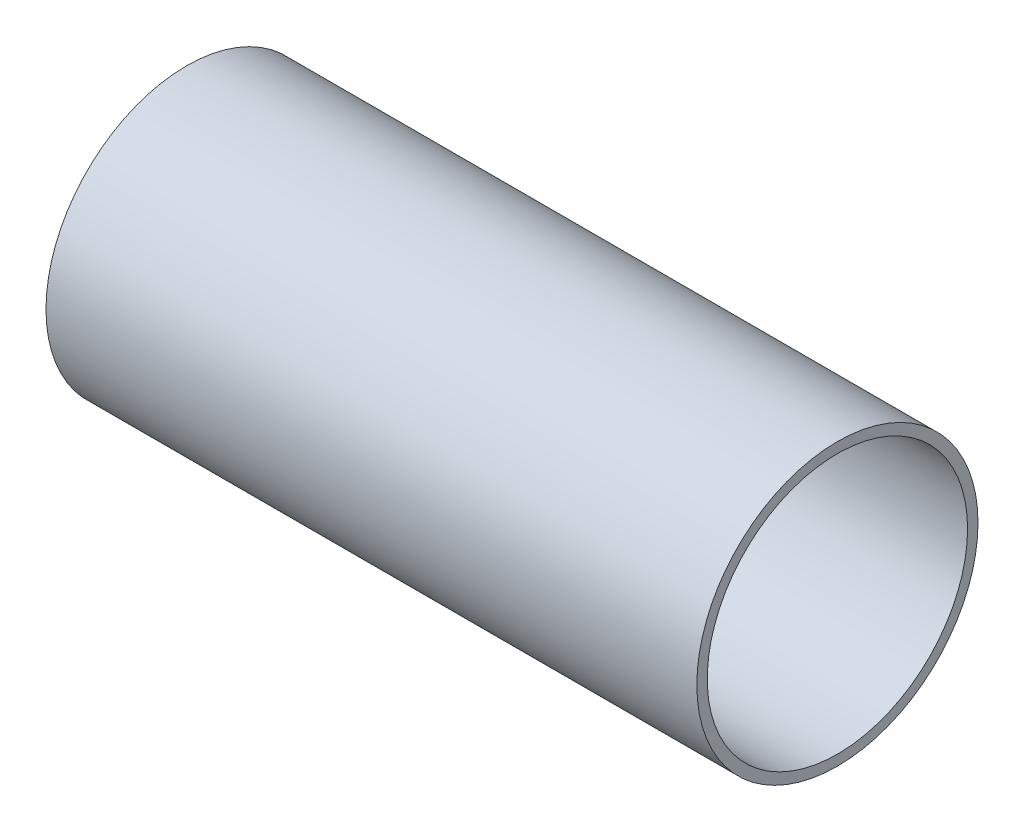
from build123d import *

# Parameters (mm, degrees)
SKETCH1_R           = 27
SKETCH1_R_2         = 25
BOSS_EXTRUDE1_DEPTH = 125


with BuildPart() as part:
    # Sketch1 → Boss-Extrude1 (new body)
    with BuildSketch(Plane(origin=(0, 0, 0), x_dir=(0, 0, -1), z_dir=(1, 0, 0))):
        Circle(SKETCH1_R)
        Circle(SKETCH1_R_2, mode=Mode.SUBTRACT)
    extrude(amount=BOSS_EXTRUDE1_DEPTH)


solid = part.part
